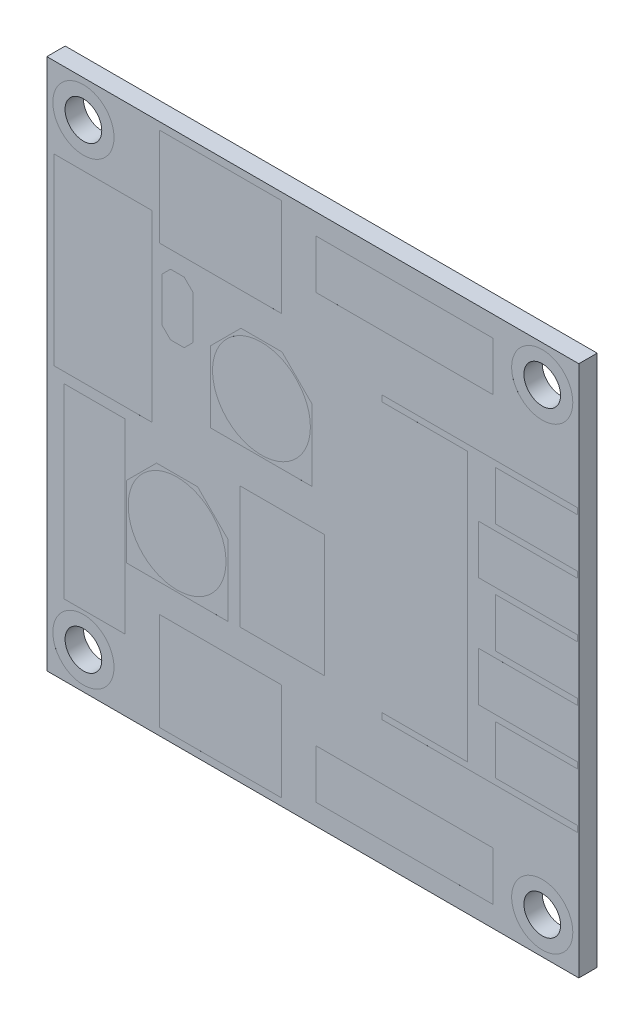
from build123d import *

# Parameters (mm, degrees)
SKETCH1_W           = 43.5
SKETCH1_H           = 43.5
SKETCH1_R           = 1.5
BOSS_EXTRUDE1_DEPTH = 1.5
SKETCH2_R           = 2.5
SKETCH2_R_2         = 1.5
CUT_EXTRUDE1_DEPTH  = 0.0001
SKETCH3_R           = 2.5
SKETCH3_R_2         = 1.5
CUT_EXTRUDE2_DEPTH  = 0.002
SKETCH4_W           = 7
SKETCH4_H           = 0.5
CUT_EXTRUDE4_DEPTH  = 0.0001
SKETCH6_W           = 8
SKETCH6_H           = 15
SKETCH6_W_2         = 10
SKETCH6_H_2         = 8
CUT_EXTRUDE5_DEPTH  = 0.0001
SKETCH8_R           = 4
CUT_EXTRUDE6_DEPTH  = 0.0001
SKETCH9_W           = 14.5
SKETCH9_H           = 4
CUT_EXTRUDE7_DEPTH  = 0.0001
SKETCH10_W          = 5
SKETCH10_H          = 15.24
CUT_EXTRUDE8_DEPTH  = 0.0001
SKETCH11_R          = 4
SKETCH11_W          = 14.5
SKETCH11_H          = 4
CUT_EXTRUDE9_DEPTH  = 0.0001
CUT_EXTRUDE10_DEPTH = 0.0001
SKETCH13_W          = 6.9
SKETCH13_H          = 10
CUT_EXTRUDE11_DEPTH = 0.0001


with BuildPart() as part:
    # Sketch1 → Boss-Extrude1 (new body)
    with BuildSketch(Plane.XY):
        Rectangle(SKETCH1_W, SKETCH1_H)
        with Locations((-18.758938316, 18.758938316)):
            Circle(SKETCH1_R, mode=Mode.SUBTRACT)
        with Locations((18.758938316, 18.758938316)):
            Circle(SKETCH1_R, mode=Mode.SUBTRACT)
        with Locations((18.758938316, -18.758938316)):
            Circle(SKETCH1_R, mode=Mode.SUBTRACT)
        with Locations((-18.758938316, -18.758938316)):
            Circle(SKETCH1_R, mode=Mode.SUBTRACT)
    extrude(amount=BOSS_EXTRUDE1_DEPTH)

    # Sketch2 → Cut-Extrude1 (cut)
    with BuildSketch(Plane.XY.offset(1.5)):
        with Locations((-18.758938316, 18.758938316)):
            Circle(SKETCH2_R)
        with Locations((-18.758938316, 18.758938316)):
            Circle(SKETCH2_R_2, mode=Mode.SUBTRACT)
        with Locations((18.758938316, 18.758938316)):
            Circle(SKETCH2_R)
        with Locations((18.758938316, 18.758938316)):
            Circle(SKETCH2_R_2, mode=Mode.SUBTRACT)
        with Locations((18.758938316, -18.758938316)):
            Circle(SKETCH2_R)
        with Locations((18.758938316, -18.758938316)):
            Circle(SKETCH2_R_2, mode=Mode.SUBTRACT)
        with Locations((-18.758938316, -18.758938316)):
            Circle(SKETCH2_R)
        with Locations((-18.758938316, -18.758938316)):
            Circle(SKETCH2_R_2, mode=Mode.SUBTRACT)
    extrude(amount=-CUT_EXTRUDE1_DEPTH, mode=Mode.SUBTRACT)

    # Sketch3 → Cut-Extrude2 (cut)
    with BuildSketch(Plane(origin=(0, 0, 0), x_dir=(-1, 0, 0), z_dir=(0, 0, -1))):
        with Locations((-18.758938316, -18.758938316)):
            Circle(SKETCH3_R)
        with Locations((-18.758938316, -18.758938316)):
            Circle(SKETCH3_R_2, mode=Mode.SUBTRACT)
        with Locations((-18.758938316, 18.758938316)):
            Circle(SKETCH3_R)
        with Locations((-18.758938316, 18.758938316)):
            Circle(SKETCH3_R_2, mode=Mode.SUBTRACT)
        with Locations((18.758938316, 18.758938316)):
            Circle(SKETCH3_R)
        with Locations((18.758938316, 18.758938316)):
            Circle(SKETCH3_R_2, mode=Mode.SUBTRACT)
        with Locations((18.758938316, -18.758938316)):
            Circle(SKETCH3_R)
        with Locations((18.758938316, -18.758938316)):
            Circle(SKETCH3_R_2, mode=Mode.SUBTRACT)
    extrude(amount=-CUT_EXTRUDE2_DEPTH, mode=Mode.SUBTRACT)

    # Sketch4 → Cut-Extrude4 (cut)
    with BuildSketch(Plane.XY.offset(1.5)):
        Polygon((14.95, 11), (21.65, 11), (21.65, 11.5), (12.65, 11.5), (12.65, 11), (12.65, -11), (12.65, -11.5), (21.65, -11.5), (21.65, -11), (14.95, -11), (14.95, -7), (21.65, -7), (21.65, -6.5), (13.55, -6.5), (13.55, -2.5), (21.65, -2.5), (21.65, -2), (14.95, -2), (14.95, 2), (21.65, 2), (21.65, 2.5), (13.55, 2.5), (13.55, 6.5), (21.65, 6.5), (21.65, 7), (14.95, 7), align=None)
        with Locations((9.15, 11.25)):
            Rectangle(SKETCH4_W, SKETCH4_H)
        with Locations((9.15, -11.25)):
            Rectangle(SKETCH4_W, SKETCH4_H)
    extrude(amount=-CUT_EXTRUDE4_DEPTH, mode=Mode.SUBTRACT)

    # Sketch6 → Cut-Extrude5 (cut)
    with BuildSketch(Plane.XY.offset(1.5)):
        with Locations((-17.15, 7.65)):
            Rectangle(SKETCH6_W, SKETCH6_H)
        with Locations((-7.55, 17.15)):
            Rectangle(SKETCH6_W_2, SKETCH6_H_2)
        with Locations((-7.55, -17.15)):
            Rectangle(SKETCH6_W_2, SKETCH6_H_2)
    extrude(amount=-CUT_EXTRUDE5_DEPTH, mode=Mode.SUBTRACT)

    # Sketch8 → Cut-Extrude6 (cut)
    with BuildSketch(Plane.XY.offset(1.5)):
        Polygon((-0.05, 7.98), (-2.52, 10.45), (-5.88, 10.45), (-8.35, 7.98), (-8.35, 2.15), (-0.05, 2.15), align=None)
        with Locations((-4.2, 6.3)):
            Circle(SKETCH8_R, mode=Mode.SUBTRACT)
    extrude(amount=-CUT_EXTRUDE6_DEPTH, mode=Mode.SUBTRACT)

    # Sketch9 → Cut-Extrude7 (cut)
    with BuildSketch(Plane.XY.offset(1.5)):
        with Locations((7.5, 18.05)):
            Rectangle(SKETCH9_W, SKETCH9_H)
    extrude(amount=-CUT_EXTRUDE7_DEPTH, mode=Mode.SUBTRACT)

    # Sketch10 → Cut-Extrude8 (cut)
    with BuildSketch(Plane.XY.offset(1.5)):
        with Locations((-17.85, -8.33)):
            Rectangle(SKETCH10_W, SKETCH10_H)
    extrude(amount=-CUT_EXTRUDE8_DEPTH, mode=Mode.SUBTRACT)

    # Sketch11 → Cut-Extrude9 (cut)
    with BuildSketch(Plane.XY.offset(1.5)):
        Polygon((-9.42, -2.55), (-12.78, -2.55), (-15.25, -5.02), (-15.25, -10.85), (-6.95, -10.85), (-6.95, -5.02), align=None)
        with Locations((-11.1, -6.7)):
            Circle(SKETCH11_R, mode=Mode.SUBTRACT)
        with Locations((7.5, -18.05)):
            Rectangle(SKETCH11_W, SKETCH11_H)
    extrude(amount=-CUT_EXTRUDE9_DEPTH, mode=Mode.SUBTRACT)

    # Sketch12 → Cut-Extrude10 (cut)
    with BuildSketch(Plane.XY.offset(1.5)):
        Polygon((-9.81, 11.04), (-10.52, 11.75), (-11.64, 11.75), (-12.35, 11.04), (-12.35, 7.46), (-11.64, 6.75), (-10.52, 6.75), (-9.81, 7.46), align=None)
    extrude(amount=-CUT_EXTRUDE10_DEPTH, mode=Mode.SUBTRACT)

    # Sketch13 → Cut-Extrude11 (cut)
    with BuildSketch(Plane.XY.offset(1.5)):
        with Locations((-2.5, -5.75)):
            Rectangle(SKETCH13_W, SKETCH13_H)
    extrude(amount=-CUT_EXTRUDE11_DEPTH, mode=Mode.SUBTRACT)


solid = part.part
